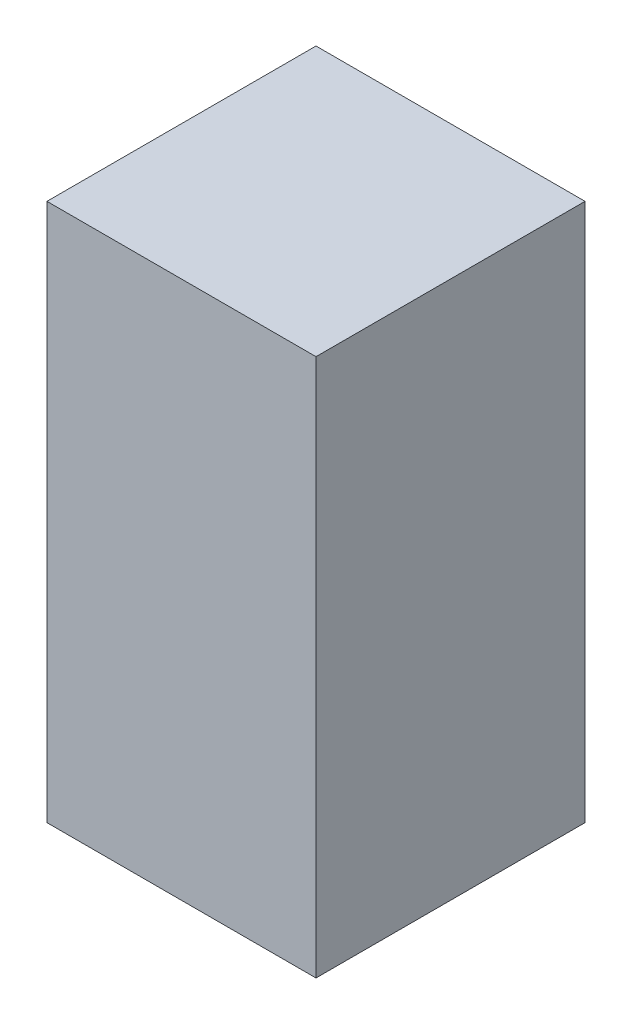
from build123d import *

# Parameters (mm, degrees)
SKETCH1_W           = 25.4
SKETCH1_H           = 25.4
BOSS_EXTRUDE1_DEPTH = 50.8


with BuildPart() as part:
    # Sketch1 → Boss-Extrude1 (new body)
    with BuildSketch(Plane(origin=(0, 0, 0), x_dir=(1, 0, 0), z_dir=(0, 1, 0))):
        Rectangle(SKETCH1_W, SKETCH1_H)
    extrude(amount=BOSS_EXTRUDE1_DEPTH)


solid = part.part
